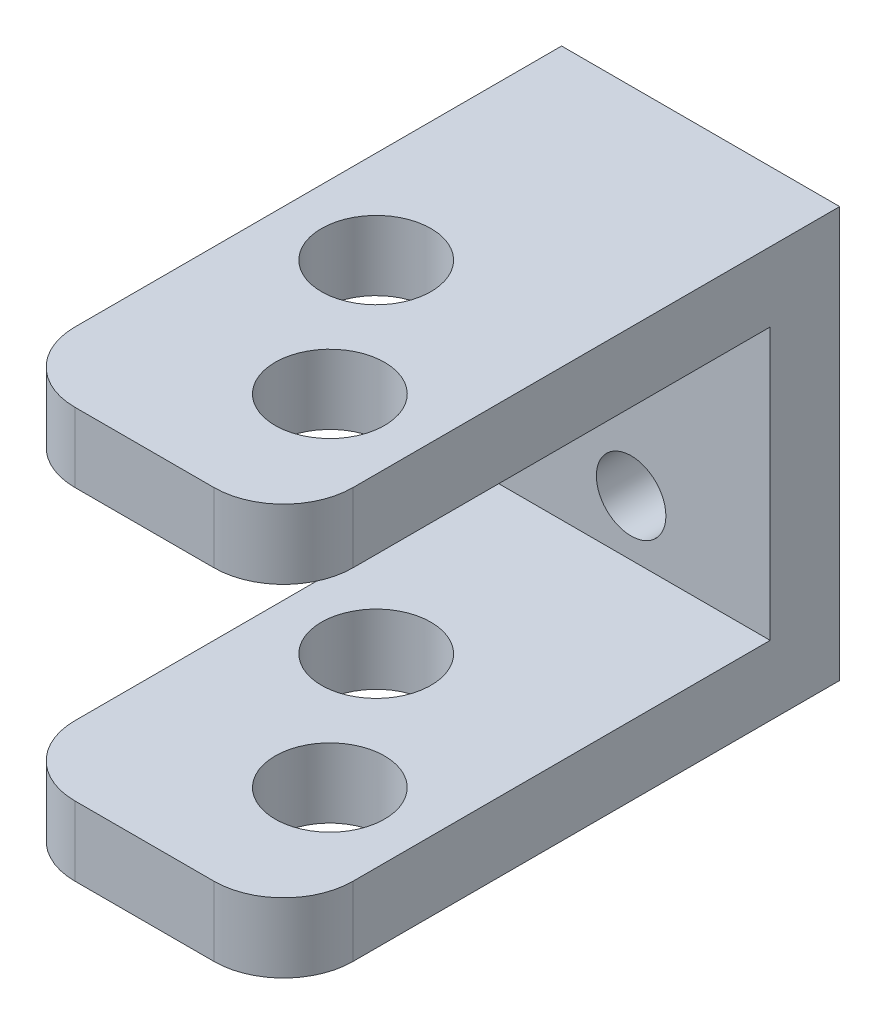
from build123d import *

# Parameters (mm, degrees)
SKETCH1_W           = 25.4
SKETCH1_H           = 6.35
SKETCH1_H_2         = 24.788235472
BOSS_EXTRUDE1_DEPTH = 6.35
SKETCH2_W           = 25.4
SKETCH2_H           = 6.35
BOSS_EXTRUDE2_DEPTH = 44.45
SKETCH3_R           = 3.175
CUT_EXTRUDE1_DEPTH  = 38.1
SKETCH6_R           = 5
CUT_EXTRUDE2_DEPTH  = 38.488235472
FILLET1_R           = 6.35


with BuildPart() as part:
    # Sketch1 → Boss-Extrude1 (new body)
    with BuildSketch(Plane.XY):
        with Locations((-12.7, -34.313235472)):
            Rectangle(SKETCH1_W, SKETCH1_H)
        with Locations((-12.7, -18.744117736)):
            Rectangle(SKETCH1_W, SKETCH1_H_2)
        with Locations((-12.7, -3.175)):
            Rectangle(SKETCH1_W, SKETCH1_H)
    extrude(amount=BOSS_EXTRUDE1_DEPTH)

    # Sketch2 → Boss-Extrude2 (add)
    with BuildSketch(Plane.XY.offset(6.35)):
        with Locations((-12.7, -3.175)):
            Rectangle(SKETCH2_W, SKETCH2_H)
        with Locations((-12.7, -34.313235472)):
            Rectangle(SKETCH2_W, SKETCH2_H)
    extrude(amount=BOSS_EXTRUDE2_DEPTH)

    # Sketch3 → Cut-Extrude1 (cut)
    with BuildSketch(Plane.XY.offset(6.35)):
        with Locations((-12.7, -26.058235472)):
            Circle(SKETCH3_R)
        with Locations((-12.7, -11.43)):
            Circle(SKETCH3_R)
    extrude(amount=-CUT_EXTRUDE1_DEPTH, mode=Mode.SUBTRACT)

    # Sketch6 → Cut-Extrude2 (cut, through all)
    with BuildSketch(Plane(origin=(0, 0, 0), x_dir=(1, 0, 0), z_dir=(0, 1, 0))):
        with Locations((-16.933333333, -25.4)):
            Circle(SKETCH6_R)
        with Locations((-8.466666667, -38.1)):
            Circle(SKETCH6_R)
    extrude(amount=-CUT_EXTRUDE2_DEPTH, mode=Mode.SUBTRACT)

    # Fillet1
    fillet1_edges = [part.edges().sort_by_distance(p)[0] for p in [
        (0, -3.175, 50.8),
        (-25.4, -3.175, 50.8),
        (-25.4, -34.313235472, 50.8),
        (0, -34.313235472, 50.8),
    ]]
    fillet(fillet1_edges, radius=FILLET1_R)


solid = part.part
